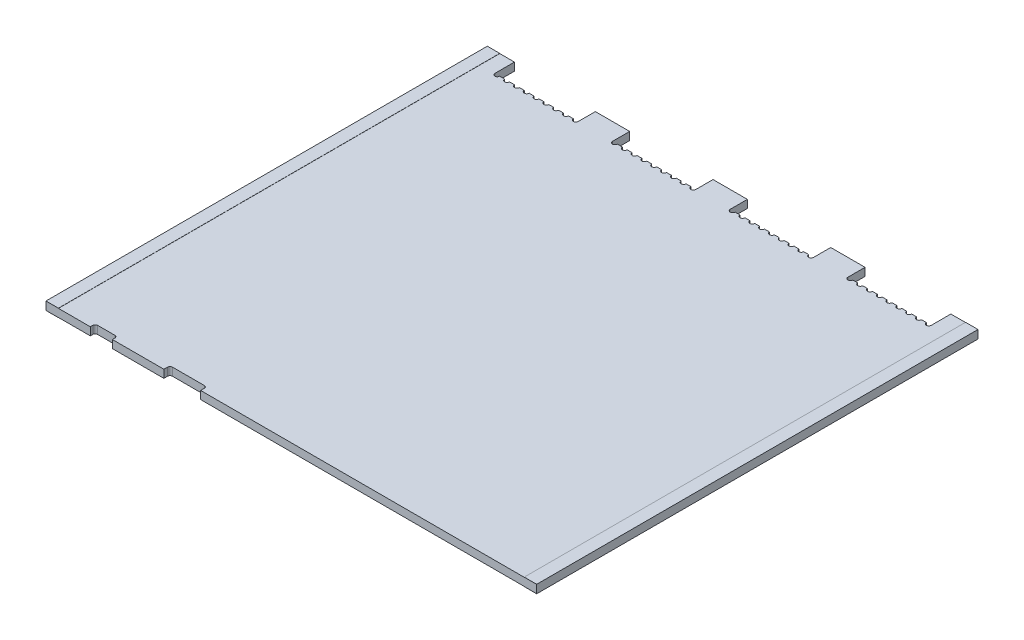
from build123d import *

# Parameters (mm, degrees)
FR4_DEPTH            = 1.61544
GOLD_PLATING_DEPTH   = 90
GOLD_PLATING_2_DEPTH = 90


with BuildPart() as part:
    # Sketch1 → FR4 (new body)
    with BuildSketch(Plane(origin=(0, 0, 0), x_dir=(1, 0, 0), z_dir=(0, 1, 0))):
        with BuildLine():
            Line((0, 90), (5.5, 90))
            Line((5.5, 90), (5.5, 86))
            ThreePointArc((5.5, 86), (6, 85.5), (6.5, 86))
            Line((6.5, 86), (7.5, 86))
            ThreePointArc((7.5, 86), (8, 85.5), (8.5, 86))
            Line((8.5, 86), (9.5, 86))
            ThreePointArc((9.5, 86), (10, 85.5), (10.5, 86))
            Line((10.5, 86), (11.5, 86))
            ThreePointArc((11.5, 86), (12, 85.5), (12.5, 86))
            Line((12.5, 86), (13.5, 86))
            ThreePointArc((13.5, 86), (14, 85.5), (14.5, 86))
            Line((14.5, 86), (15.5, 86))
            ThreePointArc((15.5, 86), (16, 85.5), (16.5, 86))
            Line((16.5, 86), (17.5, 86))
            ThreePointArc((17.5, 86), (18, 85.5), (18.5, 86))
            Line((18.5, 86), (19.5, 86))
            ThreePointArc((19.5, 86), (20, 85.5), (20.5, 86))
            Line((20.5, 86), (21.5, 86))
            ThreePointArc((21.5, 86), (22, 85.5), (22.5, 86))
            Line((22.5, 86), (22.5, 89.5))
            Line((22.5, 89.5), (29.5, 89.5))
            Line((29.5, 89.5), (29.5, 86))
            ThreePointArc((29.5, 86), (30, 85.5), (30.5, 86))
            Line((30.5, 86), (31.5, 86))
            ThreePointArc((31.5, 86), (32, 85.5), (32.5, 86))
            Line((32.5, 86), (33.5, 86))
            ThreePointArc((33.5, 86), (34, 85.5), (34.5, 86))
            Line((34.5, 86), (35.5, 86))
            ThreePointArc((35.5, 86), (36, 85.5), (36.5, 86))
            Line((36.5, 86), (37.5, 86))
            ThreePointArc((37.5, 86), (38, 85.5), (38.5, 86))
            Line((38.5, 86), (39.5, 86))
            ThreePointArc((39.5, 86), (40, 85.5), (40.5, 86))
            Line((40.5, 86), (41.5, 86))
            ThreePointArc((41.5, 86), (42, 85.5), (42.5, 86))
            Line((42.5, 86), (43.5, 86))
            ThreePointArc((43.5, 86), (44, 85.5), (44.5, 86))
            Line((44.5, 86), (45.5, 86))
            ThreePointArc((45.5, 86), (46, 85.5), (46.5, 86))
            Line((46.5, 86), (46.5, 89.5))
            Line((46.5, 89.5), (53.5, 89.5))
            Line((53.5, 89.5), (53.5, 86))
            ThreePointArc((53.5, 86), (54, 85.5), (54.5, 86))
            Line((54.5, 86), (55.5, 86))
            ThreePointArc((55.5, 86), (56, 85.5), (56.5, 86))
            Line((56.5, 86), (57.5, 86))
            ThreePointArc((57.5, 86), (58, 85.5), (58.5, 86))
            Line((58.5, 86), (59.5, 86))
            ThreePointArc((59.5, 86), (60, 85.5), (60.5, 86))
            Line((60.5, 86), (61.5, 86))
            ThreePointArc((61.5, 86), (62, 85.5), (62.5, 86))
            Line((62.5, 86), (63.5, 86))
            ThreePointArc((63.5, 86), (64, 85.5), (64.5, 86))
            Line((64.5, 86), (65.5, 86))
            ThreePointArc((65.5, 86), (66, 85.5), (66.5, 86))
            Line((66.5, 86), (67.5, 86))
            ThreePointArc((67.5, 86), (68, 85.5), (68.5, 86))
            Line((68.5, 86), (69.5, 86))
            ThreePointArc((69.5, 86), (70, 85.5), (70.5, 86))
            Line((70.5, 86), (70.5, 89.5))
            Line((70.5, 89.5), (77.5, 89.5))
            Line((77.5, 89.5), (77.5, 86))
            ThreePointArc((77.5, 86), (78, 85.5), (78.5, 86))
            Line((78.5, 86), (79.5, 86))
            ThreePointArc((79.5, 86), (80, 85.5), (80.5, 86))
            Line((80.5, 86), (81.5, 86))
            ThreePointArc((81.5, 86), (82, 85.5), (82.5, 86))
            Line((82.5, 86), (83.5, 86))
            ThreePointArc((83.5, 86), (84, 85.5), (84.5, 86))
            Line((84.5, 86), (85.5, 86))
            ThreePointArc((85.5, 86), (86, 85.5), (86.5, 86))
            Line((86.5, 86), (87.5, 86))
            ThreePointArc((87.5, 86), (88, 85.5), (88.5, 86))
            Line((88.5, 86), (89.5, 86))
            ThreePointArc((89.5, 86), (90, 85.5), (90.5, 86))
            Line((90.5, 86), (91.5, 86))
            ThreePointArc((91.5, 86), (92, 85.5), (92.5, 86))
            Line((92.5, 86), (93.5, 86))
            ThreePointArc((93.5, 86), (94, 85.5), (94.5, 86))
            Line((94.5, 86), (94.5, 90))
            Line((94.5, 90), (100, 90))
            Line((100, 90), (100, 0))
            Line((100, 0), (31.5, 0))
            Line((31.5, 0), (31.5, 0.75))
            ThreePointArc((31.5, 0.75), (31.353553391, 1.103553391), (31, 1.25))
            Line((31, 1.25), (24.5, 1.25))
            ThreePointArc((24.5, 1.25), (24.146446609, 1.103553391), (24, 0.75))
            Line((24, 0.75), (24, 0))
            Line((24, 0), (13.5, 0))
            Line((13.5, 0), (13.5, 0.4375))
            ThreePointArc((13.5, 0.4375), (13.377432717, 0.832023526), (13, 1))
            Line((13, 1), (9.5, 1))
            ThreePointArc((9.5, 1), (9.146446609, 0.853553391), (9, 0.5))
            Line((9, 0.5), (9, 0))
            Line((9, 0), (0, 0))
            Line((0, 0), (0, 90))
        make_face()
    extrude(amount=FR4_DEPTH)


with BuildPart() as body_2:
    # Sketch2 → gold-plating (new body, through all)
    with BuildSketch(Plane.XY):
        Polygon((2.5, 1.61544), (2.5, 1.651), (-0.03556, 1.651), (-0.03556, -0.03556), (2.5, -0.03556), (2.5, 0), (0, 0), (0, 1.61544), align=None)
    extrude(amount=-GOLD_PLATING_DEPTH)


with BuildPart() as body_3:
    # Sketch2 → gold-plating 2 (new body, through all)
    with BuildSketch(Plane.XY):
        Polygon((100, 1.61544), (100, 0), (97.5, 0), (97.5, -0.03556), (100.03556, -0.03556), (100.03556, 1.651), (97.5, 1.651), (97.5, 1.61544), align=None)
    extrude(amount=-GOLD_PLATING_2_DEPTH)


solid = Compound([part.part, body_2.part, body_3.part])
